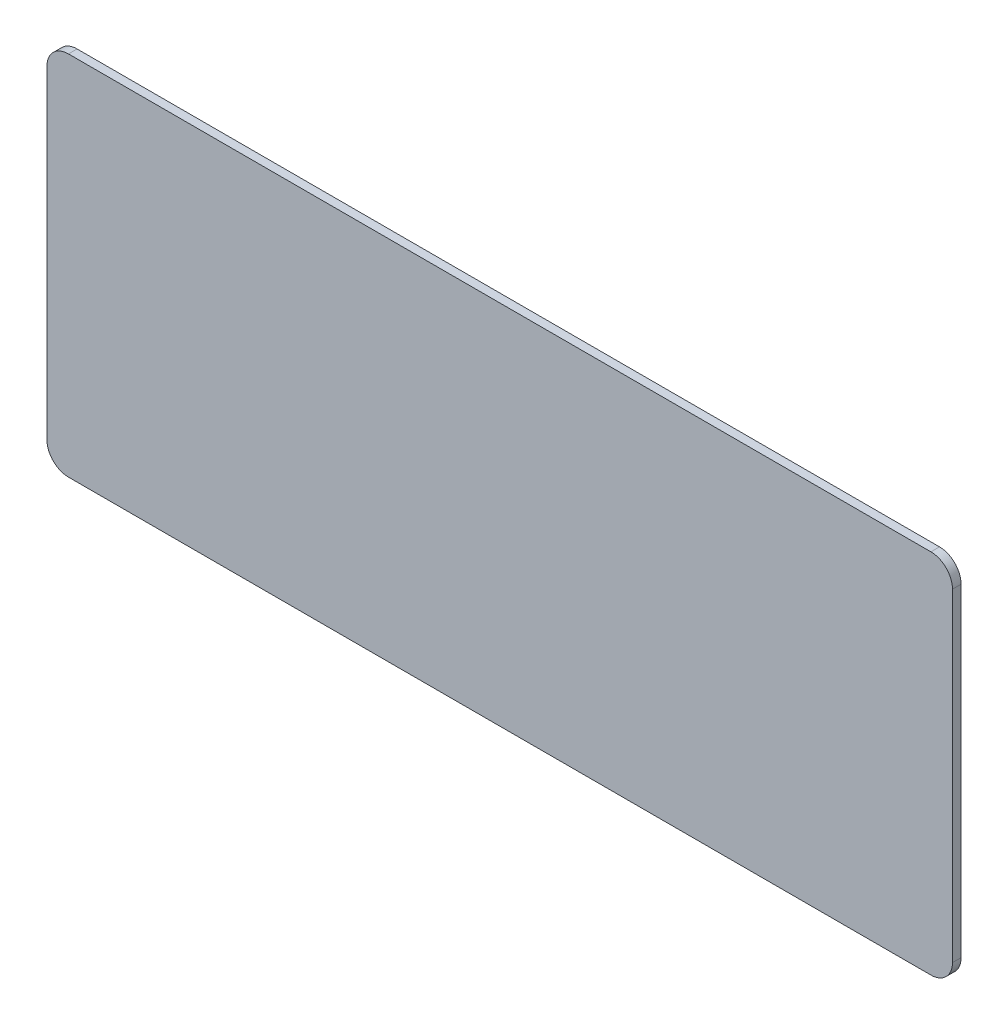
from build123d import *

# Parameters (mm, degrees)
SKETCH1_W      = 53.34
SKETCH1_H      = 21.59
EXTRUDE1_DEPTH = 0.508
FILLET1_R      = 1.27


with BuildPart() as part:
    # Sketch1 → Extrude1 (new body)
    with BuildSketch(Plane.XY):
        with Locations((26.67, 10.795)):
            Rectangle(SKETCH1_W, SKETCH1_H)
    extrude(amount=EXTRUDE1_DEPTH)

    # Fillet1
    fillet1_edges = [part.edges().sort_by_distance(p)[0] for p in [
        (0, 21.59, 0.254),
        (53.34, 21.59, 0.254),
        (53.34, 0, 0.254),
        (0, 0, 0.254),
    ]]
    fillet(fillet1_edges, radius=FILLET1_R)


solid = part.part
